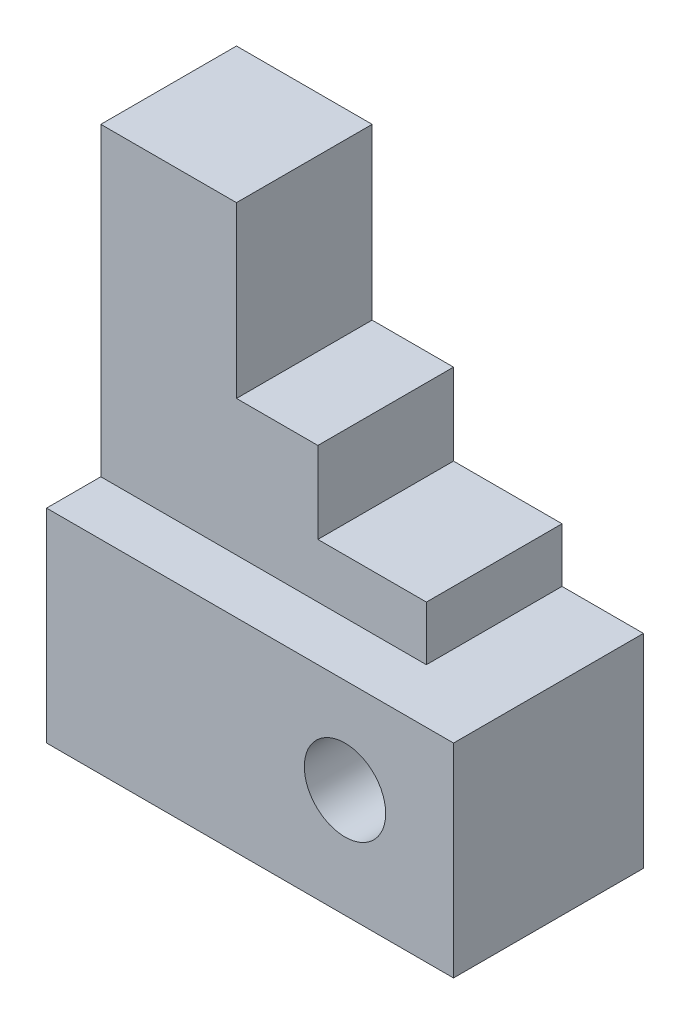
from build123d import *

# Parameters (mm, degrees)
SKETCH1_W           = 60
SKETCH1_H           = 30
SKETCH1_R           = 6
BOSS_EXTRUDE1_DEPTH = 28
SKETCH2_W           = 20
SKETCH2_H           = 25
BOSS_EXTRUDE2_DEPTH = 20


with BuildPart() as part:
    # Sketch1 → Boss-Extrude1 (new body)
    with BuildSketch(Plane.XY):
        Rectangle(SKETCH1_W, SKETCH1_H)
        with Locations((14, 1)):
            Circle(SKETCH1_R, mode=Mode.SUBTRACT)
    extrude(amount=BOSS_EXTRUDE1_DEPTH)

    # Sketch2 → Boss-Extrude2 (add)
    with BuildSketch(Plane(origin=(0, 0, 0), x_dir=(-1, 0, 0), z_dir=(0, 0, -1))):
        Polygon((-18, 15), (30, 15), (30, 23), (-2, 23), (-18, 23), align=None)
        Polygon((-2, 23), (30, 23), (30, 35), (10, 35), (-2, 35), align=None)
        with Locations((20, 47.5)):
            Rectangle(SKETCH2_W, SKETCH2_H)
    extrude(amount=-BOSS_EXTRUDE2_DEPTH)


solid = part.part
